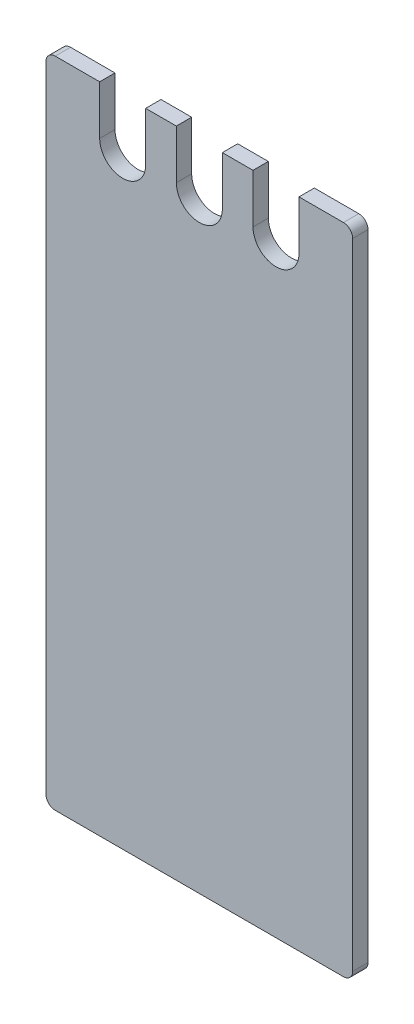
from build123d import *

# Parameters (mm, degrees)
BOSS_EXTRUDE1_DEPTH = 2.5
FILLET1_R           = 3


with BuildPart() as part:
    # Sketch1 → Boss-Extrude1 (new body, symmetric)
    with BuildSketch(Plane.XY):
        with BuildLine():
            Line((-7.5, 213), (-17.5, 213))
            Line((-17.5, 213), (-17.5, 197))
            ThreePointArc((-17.5, 197), (-25, 189.5), (-32.5, 197))
            Line((-32.5, 197), (-32.5, 213))
            Line((-32.5, 213), (-50, 213))
            Line((-50, 213), (-50, 0))
            Line((-50, 0), (50, 0))
            Line((50, 0), (50, 213))
            Line((50, 213), (32.5, 213))
            Line((32.5, 213), (32.5, 197))
            ThreePointArc((32.5, 197), (25, 189.5), (17.5, 197))
            Line((17.5, 197), (17.5, 213))
            Line((17.5, 213), (7.5, 213))
            Line((7.5, 213), (7.5, 197))
            ThreePointArc((7.5, 197), (0, 189.5), (-7.5, 197))
            Line((-7.5, 197), (-7.5, 213))
        make_face()
    extrude(amount=BOSS_EXTRUDE1_DEPTH, both=True)

    # Fillet1
    fillet1_edges = [part.edges().sort_by_distance(p)[0] for p in [
        (50, 213, 0),
        (50, 0, 0),
        (-50, 0, 0),
        (-50, 213, 0),
    ]]
    fillet(fillet1_edges, radius=FILLET1_R)


solid = part.part
